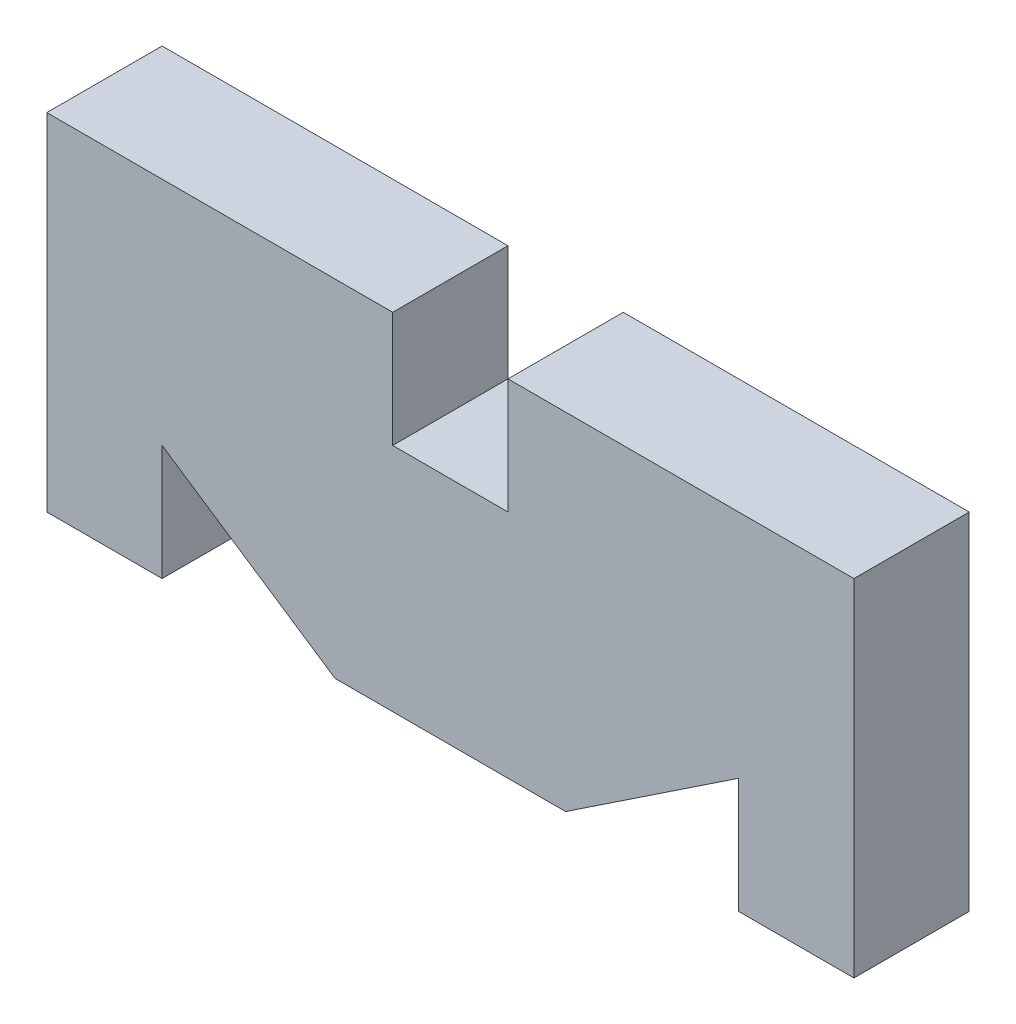
from build123d import *

# Parameters (mm, degrees)
BOSS_EXTRUDE1_DEPTH = 10


with BuildPart() as part:
    # Sketch1 → Boss-Extrude1 (new body)
    with BuildSketch(Plane.XY):
        Polygon((-35, -15), (-25, -15), (-25, -5), (-10, -15), (10, -15), (25, -5), (25, -15), (35, -15), (35, 15), (5, 15), (5, 5), (-5, 5), (-5, 15), (-35, 15), align=None)
    extrude(amount=BOSS_EXTRUDE1_DEPTH)


solid = part.part
